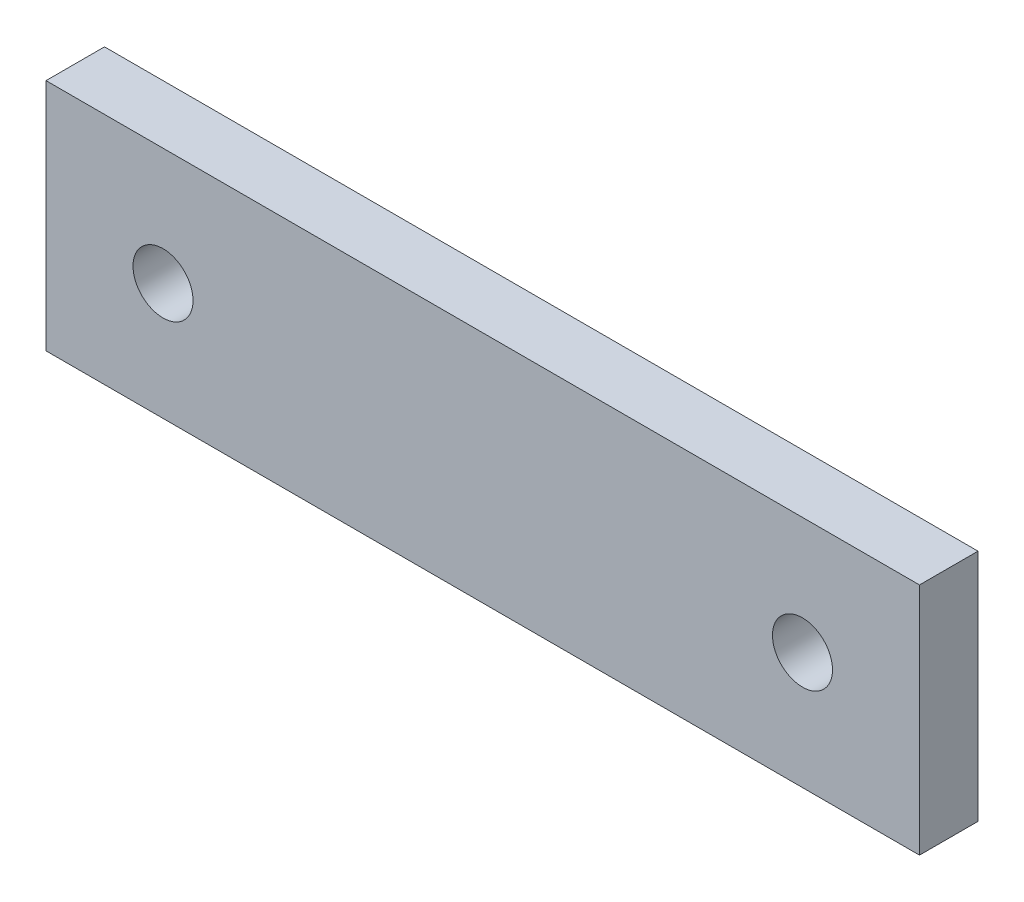
from build123d import *

# Parameters (mm, degrees)
SKETCH1_W           = 94.8
SKETCH1_H           = 25.4
SKETCH1_R           = 3.25755
BOSS_EXTRUDE1_DEPTH = 6.35


with BuildPart() as part:
    # Sketch1 → Boss-Extrude1 (new body)
    with BuildSketch(Plane.XY):
        Rectangle(SKETCH1_W, SKETCH1_H)
        with Locations((34.7, 0)):
            Circle(SKETCH1_R, mode=Mode.SUBTRACT)
        with Locations((-34.7, 0)):
            Circle(SKETCH1_R, mode=Mode.SUBTRACT)
    extrude(amount=BOSS_EXTRUDE1_DEPTH)


solid = part.part
